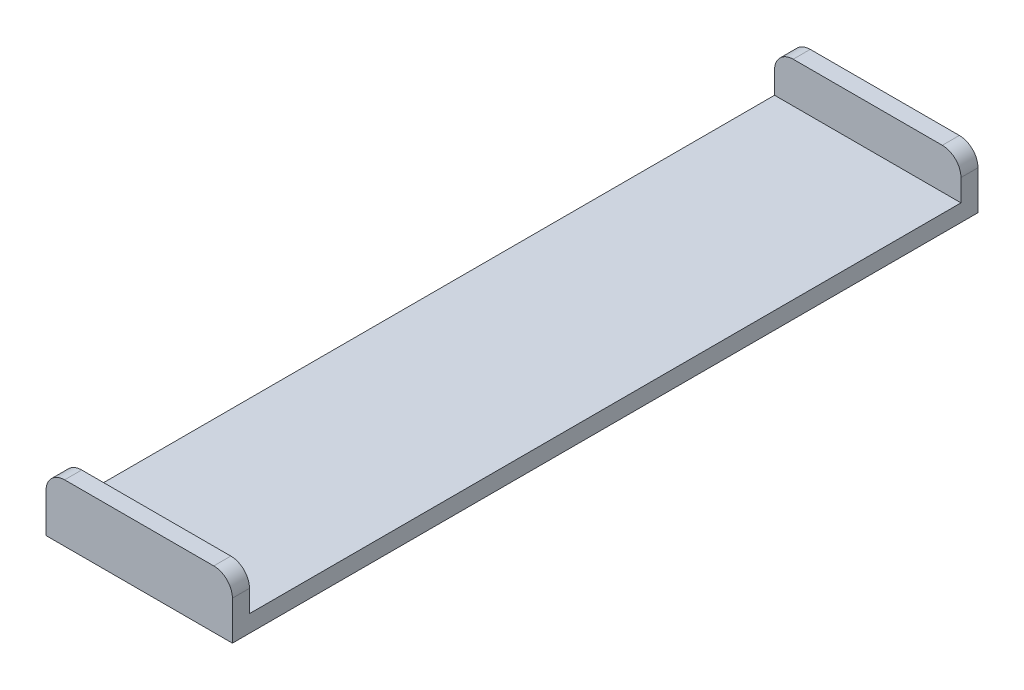
from build123d import *

# Parameters (mm, degrees)
SKETCH1_W           = 50.8
SKETCH1_H           = 203.2
BOSS_EXTRUDE1_DEPTH = 4.6482
SKETCH2_W           = 50.8
SKETCH2_H           = 4.6482
BOSS_EXTRUDE2_DEPTH = 11.049
FILLET1_R           = 5.08


with BuildPart() as part:
    # Sketch1 → Boss-Extrude1 (new body)
    with BuildSketch(Plane(origin=(0, 0, 0), x_dir=(1, 0, 0), z_dir=(0, 1, 0))):
        with Locations((25.4, 101.6)):
            Rectangle(SKETCH1_W, SKETCH1_H)
    extrude(amount=BOSS_EXTRUDE1_DEPTH)

    # Sketch2 → Boss-Extrude2 (add)
    with BuildSketch(Plane(origin=(0, 4.6482, 0), x_dir=(1, 0, 0), z_dir=(0, 1, 0))):
        with Locations((25.4, 2.3241)):
            Rectangle(SKETCH2_W, SKETCH2_H)
        with Locations((25.4, 200.8759)):
            Rectangle(SKETCH2_W, SKETCH2_H)
    extrude(amount=BOSS_EXTRUDE2_DEPTH)

    # Fillet1
    fillet1_edges = [part.edges().sort_by_distance(p)[0] for p in [
        (0, 15.6972, -2.3241),
        (50.8, 15.6972, -2.3241),
        (0, 15.6972, -200.8759),
        (50.8, 15.6972, -200.8759),
    ]]
    fillet(fillet1_edges, radius=FILLET1_R)


solid = part.part
